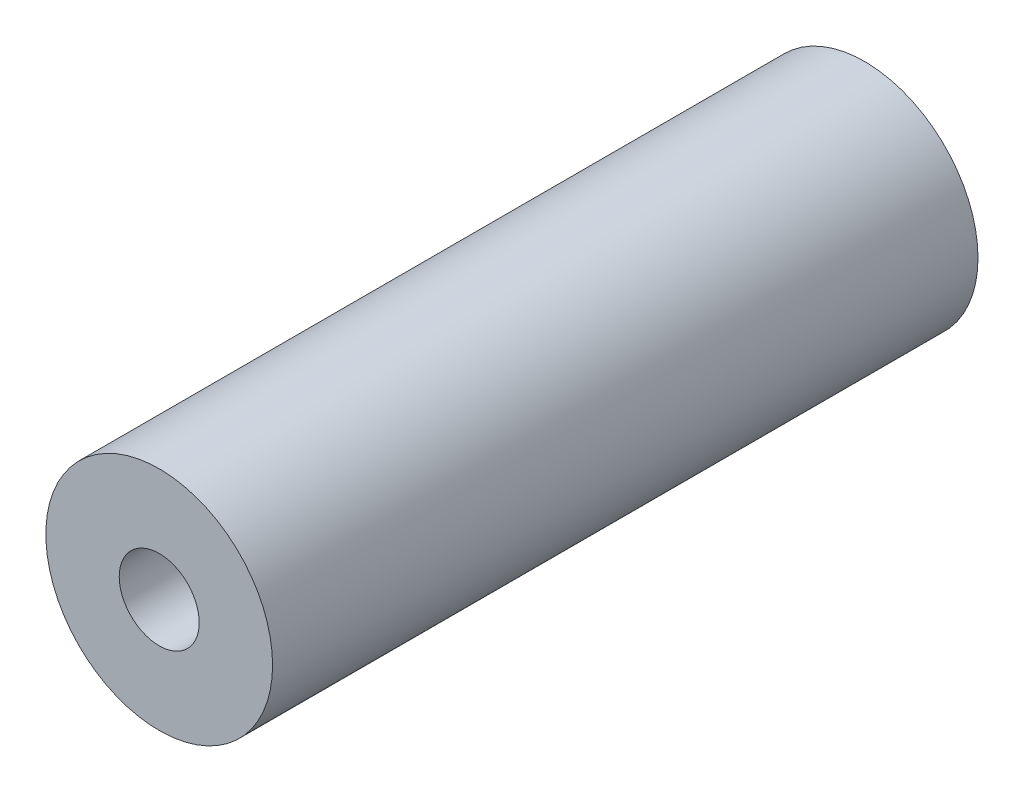
from build123d import *

# Parameters (mm, degrees)
ESBO_O1_R                = 9
RESSALTO_EXTRUS_O1_DEPTH = 56
ESBO_O2_R                = 5.615
CORTE_EXTRUS_O1_DEPTH    = 7.54
ESBO_O3_R                = 3.175
CORTE_EXTRUS_O2_DEPTH    = 49.46


with BuildPart() as part:
    # Esboço1 → Ressalto-extrusão1 (new body)
    with BuildSketch(Plane.XY):
        Circle(ESBO_O1_R)
    extrude(amount=RESSALTO_EXTRUS_O1_DEPTH)

    # Esboço2 → Corte-extrusão1 (cut)
    with BuildSketch(Plane(origin=(0, 0, 0), x_dir=(-1, 0, 0), z_dir=(0, 0, -1))):
        Circle(ESBO_O2_R)
    extrude(amount=-CORTE_EXTRUS_O1_DEPTH, mode=Mode.SUBTRACT)

    # Esboço3 → Corte-extrusão2 (cut, through all)
    with BuildSketch(Plane(origin=(0, 0, 7.54), x_dir=(-1, 0, 0), z_dir=(0, 0, -1))):
        Circle(ESBO_O3_R)
    extrude(amount=-CORTE_EXTRUS_O2_DEPTH, mode=Mode.SUBTRACT)


solid = part.part
